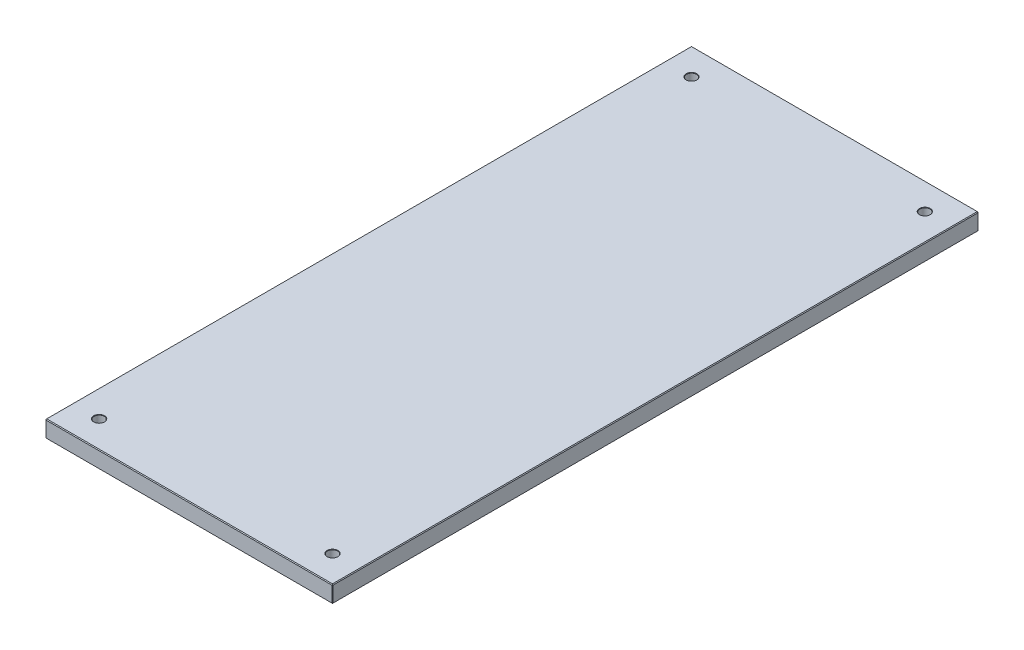
from build123d import *

# Parameters (mm, degrees)
SKETCH1_W                        = 203.2
SKETCH1_H                        = 457.2
BOSS_EXTRUDE1_DEPTH              = 6
F_1_4_CLEARANCE_HOLE1_AT_2_COUNT = 2
F_1_4_CLEARANCE_HOLE1_AT_2_PITCH = 165.1
F_1_4_CLEARANCE_HOLE1_AT_3_COUNT = 2
F_1_4_CLEARANCE_HOLE1_AT_3_PITCH = 450.447355415
F_1_4_CLEARANCE_HOLE1_AT_4_COUNT = 2
F_1_4_CLEARANCE_HOLE1_AT_4_PITCH = 419.1
CHAMFER1_SIZE                    = 0.508


with BuildPart() as part:
    # Sketch1 → Boss-Extrude1 (new, symmetric)
    with BuildSketch(Plane(origin=(0, 0, 0), x_dir=(1, 0, 0), z_dir=(0, 1, 0))):
        Rectangle(SKETCH1_W, SKETCH1_H)
    extrude(amount=BOSS_EXTRUDE1_DEPTH, both=True)

    # Sketch4 → 1_4 Clearance Hole1 (revolve, cut)
    with BuildSketch(Plane(origin=(-82.55, 6, -209.55), x_dir=(0, 0, 1), z_dir=(1, 0, 0))):
        Polygon((0, 0), (0, 12), (3.82524, 12), (3.57124, 11.746), (3.57124, 0.254), (3.82524, 0), align=None)
    f_1_4_clearance_hole1 = revolve(axis=Axis((-82.55, 12.35, -209.55), (0, -1, 0)), mode=Mode.SUBTRACT)

    # 1_4 Clearance Hole1 at 2: 1_4 Clearance Hole1 ×2
    with Locations(*[(i * F_1_4_CLEARANCE_HOLE1_AT_2_PITCH, 0, 0) for i in range(1, F_1_4_CLEARANCE_HOLE1_AT_2_COUNT)]):
        add(f_1_4_clearance_hole1, mode=Mode.SUBTRACT)

    # 1_4 Clearance Hole1 at 3: 1_4 Clearance Hole1 ×2
    with Locations(*[Vector(0.36652451838249067, 0, 0.9304083928170915) * (i * F_1_4_CLEARANCE_HOLE1_AT_3_PITCH) for i in range(1, F_1_4_CLEARANCE_HOLE1_AT_3_COUNT)]):
        add(f_1_4_clearance_hole1, mode=Mode.SUBTRACT)

    # 1_4 Clearance Hole1 at 4: 1_4 Clearance Hole1 ×2
    with Locations(*[(0, 0, i * F_1_4_CLEARANCE_HOLE1_AT_4_PITCH) for i in range(1, F_1_4_CLEARANCE_HOLE1_AT_4_COUNT)]):
        add(f_1_4_clearance_hole1, mode=Mode.SUBTRACT)

    # Chamfer1
    chamfer1_edges = [part.edges().sort_by_distance(p)[0] for p in [
        (101.6, 6, 0),
        (101.6, -6, 0),
        (101.6, 0, -228.6),
        (0, 6, -228.6),
        (0, -6, -228.6),
        (-101.6, 0, -228.6),
        (-101.6, 6, 0),
        (-101.6, -6, 0),
        (-101.6, 0, 228.6),
        (0, 6, 228.6),
        (101.6, 0, 228.6),
        (0, -6, 228.6),
    ]]
    chamfer(chamfer1_edges, length=CHAMFER1_SIZE)


solid = part.part
